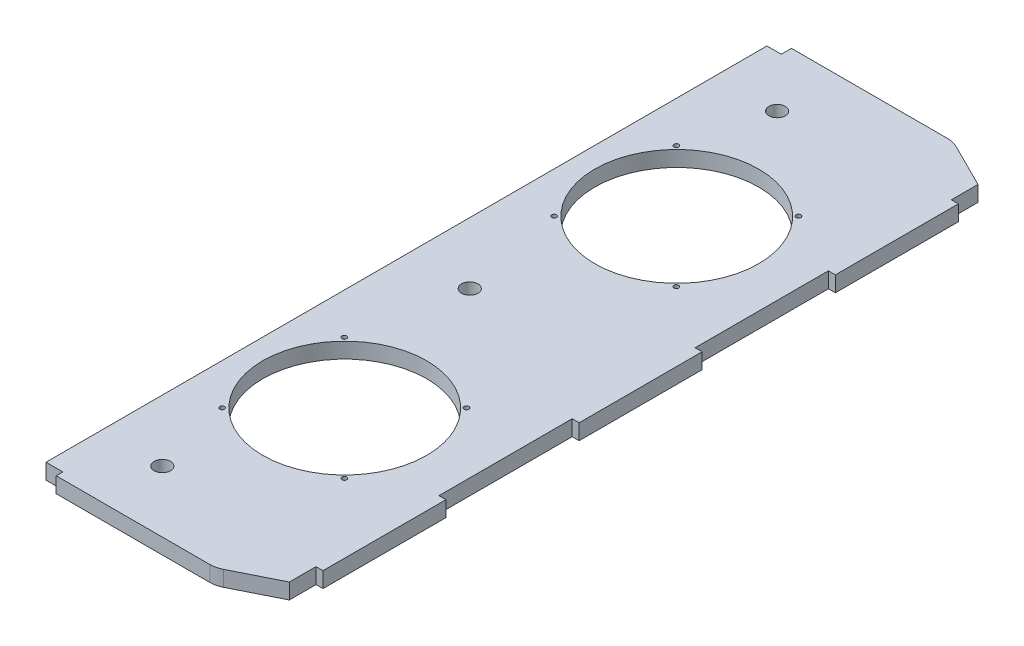
from build123d import *

# Parameters (mm, degrees)
SKETCH1_W                    = 139.7
SKETCH1_H                    = 457.2
SKETCH1_R                    = 50.8
SKETCH1_R_2                  = 5.08
BOSS_EXTRUDE1_DEPTH          = 9.652
SKETCH4_W                    = 10.452383168
SKETCH4_H                    = 4.1148
SKETCH4_W_2                  = 8.864883168
SKETCH4_H_2                  = 6.35
CUT_EXTRUDE1_DEPTH           = 10.652
CHAMFER1_SIZE                = 15.24
CHAMFER1_SIZE2               = 30.48
CHAMFER2_SIZE                = 30.48
CHAMFER2_SIZE2               = 15.24
FILLET2_R                    = 15.24
SKETCH5_W                    = 76.2
SKETCH5_H                    = 9.652
BOSS_EXTRUDE2_DEPTH          = 4.318
F_3_0_3_DIAMETER_HOLE1_D     = 3
F_3_0_3_DIAMETER_HOLE1_DEPTH = 9.652


with BuildPart() as part:
    # Sketch1 → Boss-Extrude1 (new body)
    with BuildSketch(Plane(origin=(0, 0, 0), x_dir=(1, 0, 0), z_dir=(0, 1, 0))):
        with Locations((69.85, 228.6)):
            Rectangle(SKETCH1_W, SKETCH1_H)
        with Locations((63.5, 125.73)):
            Circle(SKETCH1_R, mode=Mode.SUBTRACT)
        with Locations((38.1, 38.1)):
            Circle(SKETCH1_R_2, mode=Mode.SUBTRACT)
        with Locations((38.1, 419.1)):
            Circle(SKETCH1_R_2, mode=Mode.SUBTRACT)
        with Locations((63.5, 331.47)):
            Circle(SKETCH1_R, mode=Mode.SUBTRACT)
        with Locations((38.1, 228.6)):
            Circle(SKETCH1_R_2, mode=Mode.SUBTRACT)
    extrude(amount=BOSS_EXTRUDE1_DEPTH)

    # Sketch4 → Cut-Extrude1 (cut, through all)
    with BuildSketch(Plane(origin=(0, 9.652, 0), x_dir=(1, 0, 0), z_dir=(0, 1, 0))):
        with Locations((5.226191584, 2.0574)):
            Rectangle(SKETCH4_W, SKETCH4_H)
        with Locations((4.432441584, 454.025)):
            Rectangle(SKETCH4_W_2, SKETCH4_H_2)
    extrude(amount=-CUT_EXTRUDE1_DEPTH, mode=Mode.SUBTRACT)

    # Chamfer1
    chamfer1_edges = [part.edges().sort_by_distance(p)[0] for p in [
        (139.7, 4.826, -457.2),
    ]]
    chamfer1_side = [part.faces().sort_by_distance(p)[0] for p in [
        (139.7, 4.826, -228.6),
    ]]
    chamfer(chamfer1_edges, length=CHAMFER1_SIZE, length2=CHAMFER1_SIZE2, reference=chamfer1_side[0])

    # Chamfer2
    chamfer2_edges = [part.edges().sort_by_distance(p)[0] for p in [
        (139.7, 4.826, 0),
    ]]
    chamfer2_side = [part.faces().sort_by_distance(p)[0] for p in [
        (75.076191584, 4.826, 0),
    ]]
    chamfer(chamfer2_edges, length=CHAMFER2_SIZE, length2=CHAMFER2_SIZE2, reference=chamfer2_side[0])

    # Fillet2
    fillet2_edges = [part.edges().sort_by_distance(p)[0] for p in [
        (109.22, 4.826, -457.2),
        (109.22, 4.826, 0),
    ]]
    fillet(fillet2_edges, radius=FILLET2_R)

    # Sketch5 → Boss-Extrude2 (add)
    with BuildSketch(Plane(origin=(139.7, 0, 0), x_dir=(0, 0, -1), z_dir=(1, 0, 0))):
        with Locations((69.85, 4.826)):
            Rectangle(SKETCH5_W, SKETCH5_H)
        with Locations((228.6, 4.826)):
            Rectangle(SKETCH5_W, SKETCH5_H)
        with Locations((387.35, 4.826)):
            Rectangle(SKETCH5_W, SKETCH5_H)
    extrude(amount=BOSS_EXTRUDE2_DEPTH)

    # Ø3.0 (3) Diameter Hole1
    with Locations(Plane(origin=(0, 9.652, 0), x_dir=(1, 0, 0), z_dir=(0, 1, 0))):
        with Locations((101.092, 87.884), (25.4, 87.884), (25.4, 163.576), (101.092, 163.576)):
            f_3_0_3_diameter_hole1 = Hole(F_3_0_3_DIAMETER_HOLE1_D / 2, depth=F_3_0_3_DIAMETER_HOLE1_DEPTH)

    # Mirror1: Ø3.0 (3) Diameter Hole1 across plane
    add(f_3_0_3_diameter_hole1.mirror(Plane.XY.offset(-228.6)), mode=Mode.SUBTRACT)


solid = part.part
